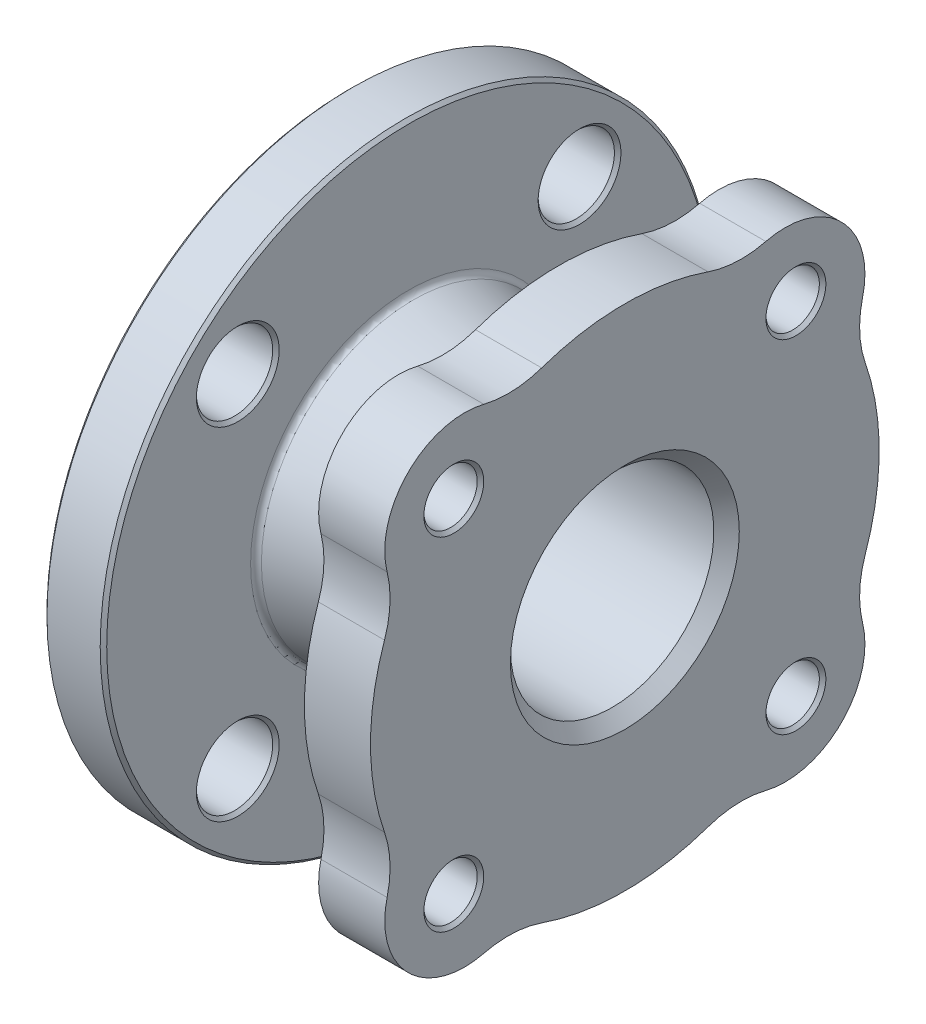
from build123d import *

# Parameters (mm, degrees)
SKETCH2_R           = 6.6675
SKETCH2_R_2         = 25.4
BOSS_EXTRUDE2_DEPTH = 16.51
CUT_EXTRUDE1_REACH  = 129.898
SKETCH3_R           = 9.525
CHAMFER1_SIZE       = 0.8128
CHAMFER2_SIZE       = 3.175
FILLET1_R           = 1.524


with BuildPart() as part:
    # Sketch1 → Revolve1 (revolve)
    with BuildSketch(Plane.XY, mode=Mode.PRIVATE) as revolve1_sk:
        Polygon((0, 25.4), (53.975, 25.4), (53.975, 47.625), (52.3748, 46.0248), (52.3748, 34.29), (35.052, 34.29), (16.51, 38.231223766), (16.51, 76.2), (1.6002, 76.2), (1.6002, 47.7012), (0, 46.101), align=None)
    revolve(revolve1_sk.sketch.rotate(Axis((0, 0, 0), (1, 0, 0)), 90), axis=Axis((0, 0, 0), (1, 0, 0)))

    # Sketch2 → Boss-Extrude2 (add)
    with BuildSketch(Plane(origin=(53.975, 0, 0), x_dir=(0, 0, -1), z_dir=(1, 0, 0))):
        with BuildLine():
            ThreePointArc((-60.006129061, 20.772926495), (-63.5, 0), (-60.006129061, -20.772926495))
            ThreePointArc((-60.006129061, -20.772926495), (-58.634269802, -27.940016869), (-59.356714755, -35.20137043))
            ThreePointArc((-59.356714755, -35.20137043), (-54.10400211, -54.10400211), (-35.20137043, -59.356714755))
            ThreePointArc((-35.20137043, -59.356714755), (-27.940016869, -58.634269802), (-20.772926495, -60.006129061))
            ThreePointArc((-20.772926495, -60.006129061), (0, -63.5), (20.772926495, -60.006129061))
            ThreePointArc((20.772926495, -60.006129061), (27.940016869, -58.634269802), (35.20137043, -59.356714755))
            ThreePointArc((35.20137043, -59.356714755), (54.10400211, -54.10400211), (59.356714755, -35.20137043))
            ThreePointArc((59.356714755, -35.20137043), (58.634269802, -27.940016869), (60.006129061, -20.772926495))
            ThreePointArc((60.006129061, -20.772926495), (63.5, 0), (60.006129061, 20.772926495))
            ThreePointArc((60.006129061, 20.772926495), (58.634269802, 27.940016869), (59.356714755, 35.20137043))
            ThreePointArc((59.356714755, 35.20137043), (54.10400211, 54.10400211), (35.20137043, 59.356714755))
            ThreePointArc((35.20137043, 59.356714755), (27.940016869, 58.634269802), (20.772926495, 60.006129061))
            ThreePointArc((20.772926495, 60.006129061), (0, 63.5), (-20.772926495, 60.006129061))
            ThreePointArc((-20.772926495, 60.006129061), (-27.940016869, 58.634269802), (-35.20137043, 59.356714755))
            ThreePointArc((-35.20137043, 59.356714755), (-54.10400211, 54.10400211), (-59.356714755, 35.20137043))
            ThreePointArc((-59.356714755, 35.20137043), (-58.634269802, 27.940016869), (-60.006129061, 20.772926495))
        make_face()
        with Locations((-42.706424702, 42.706424702)):
            Circle(SKETCH2_R, mode=Mode.SUBTRACT)
        with Locations(Location((42.706424702, 42.706424702, 0), (0, 0, 180))):
            Circle(SKETCH2_R, mode=Mode.SUBTRACT)
        with Locations((42.706424702, -42.706424702)):
            Circle(SKETCH2_R, mode=Mode.SUBTRACT)
        with Locations(Location((-42.706424702, -42.706424702, 0), (0, 0, 180))):
            Circle(SKETCH2_R, mode=Mode.SUBTRACT)
        with Locations(Location((0, 0, 0), (0, 0, 180))):
            Circle(SKETCH2_R_2, mode=Mode.SUBTRACT)
    extrude(amount=BOSS_EXTRUDE2_DEPTH)

    # Sketch3 → Cut-Extrude1 (cut, up to next)
    with BuildSketch(Plane.ZY.offset(-1.6002), mode=Mode.PRIVATE) as cut_extrude1_sk1:
        with Locations((42.656216575, 42.656216575)):
            Circle(SKETCH3_R)
    cut_extrude1_tool1 = extrude(cut_extrude1_sk1.sketch, amount=-CUT_EXTRUDE1_REACH, mode=Mode.PRIVATE) & part.part
    # Sketch3 → Cut-Extrude1 (cut, up to next)
    with BuildSketch(Plane.ZY.offset(-1.6002), mode=Mode.PRIVATE) as cut_extrude1_sk2:
        with Locations((-42.656216575, 42.656216575)):
            Circle(SKETCH3_R)
    cut_extrude1_tool2 = extrude(cut_extrude1_sk2.sketch, amount=-CUT_EXTRUDE1_REACH, mode=Mode.PRIVATE) & part.part
    # Sketch3 → Cut-Extrude1 (cut, up to next)
    with BuildSketch(Plane.ZY.offset(-1.6002), mode=Mode.PRIVATE) as cut_extrude1_sk3:
        with Locations((42.656216575, -42.656216575)):
            Circle(SKETCH3_R)
    cut_extrude1_tool3 = extrude(cut_extrude1_sk3.sketch, amount=-CUT_EXTRUDE1_REACH, mode=Mode.PRIVATE) & part.part
    # Sketch3 → Cut-Extrude1 (cut, up to next)
    with BuildSketch(Plane.ZY.offset(-1.6002), mode=Mode.PRIVATE) as cut_extrude1_sk4:
        with Locations((-42.656216575, -42.656216575)):
            Circle(SKETCH3_R)
    cut_extrude1_tool4 = extrude(cut_extrude1_sk4.sketch, amount=-CUT_EXTRUDE1_REACH, mode=Mode.PRIVATE) & part.part
    add(cut_extrude1_tool1.solids().sort_by_distance((1.6002, 42.656217, 42.656217))[0], mode=Mode.SUBTRACT)
    add(cut_extrude1_tool2.solids().sort_by_distance((1.6002, 42.656217, -42.656217))[0], mode=Mode.SUBTRACT)
    add(cut_extrude1_tool3.solids().sort_by_distance((1.6002, -42.656217, 42.656217))[0], mode=Mode.SUBTRACT)
    add(cut_extrude1_tool4.solids().sort_by_distance((1.6002, -42.656217, -42.656217))[0], mode=Mode.SUBTRACT)

    # Chamfer1
    chamfer1_edges = [part.edges().sort_by_distance(p)[0] for p in [
        (53.975, -42.706424702, 36.038924702),
        (53.975, 42.706424702, -49.373924702),
        (53.975, 42.706424702, 49.373924702),
        (53.975, -42.706424702, -36.038924702),
        (70.485, 42.706424702, 49.373924702),
        (70.485, 42.706424702, -49.373924702),
        (70.485, -42.706424702, -36.038924702),
        (70.485, -42.706424702, 36.038924702),
        (1.6002, 42.656216575, 33.131216575),
        (16.51, 42.656216575, 33.131216575),
        (1.6002, 42.656216575, -52.181216575),
        (16.51, 42.656216575, -52.181216575),
        (1.6002, -42.656216575, 33.131216575),
        (16.51, -42.656216575, 33.131216575),
        (1.6002, -42.656216575, -52.181216575),
        (16.51, -42.656216575, -52.181216575),
        (1.6002, 0, -76.2),
        (16.51, 0, -76.2),
    ]]
    chamfer(chamfer1_edges, length=CHAMFER1_SIZE)

    # Chamfer2
    chamfer2_edges = [part.edges().sort_by_distance(p)[0] for p in [
        (0, 0, -25.4),
        (70.485, 0, -25.4),
    ]]
    chamfer(chamfer2_edges, length=CHAMFER2_SIZE)

    # Fillet1
    fillet1_edges = [part.edges().sort_by_distance(p)[0] for p in [
        (52.3748, 0, -34.29),
        (16.51, 0, -38.231223766),
    ]]
    fillet(fillet1_edges, radius=FILLET1_R)


solid = part.part
